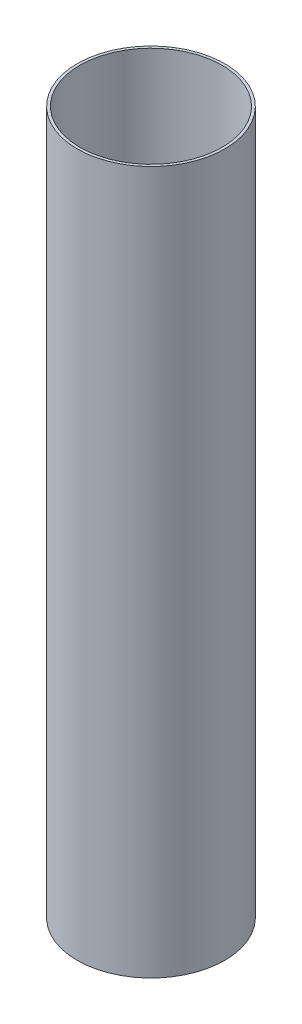
from build123d import *

# Parameters (mm, degrees)
SKETCH1_R               = 12
BOSS_EXTRUDE1_DEPTH     = 114.25
SKETCH2_R               = 11.565
CUT_EXTRUDE1_DEPTH      = 40
SKETCH3_R               = 3.3
CUT_EXTRUDE2_DEPTH      = 1
CUT_EXTRUDE2_DEPTH_BACK = 115.25


with BuildPart() as part:
    # Sketch1 → Boss-Extrude1 (new body)
    with BuildSketch(Plane(origin=(0, 0, 0), x_dir=(1, 0, 0), z_dir=(0, 1, 0))):
        Circle(SKETCH1_R)
    extrude(amount=BOSS_EXTRUDE1_DEPTH)

    # Sketch2 → Cut-Extrude1 (cut)
    with BuildSketch(Plane(origin=(0, 114.25, 0), x_dir=(1, 0, 0), z_dir=(0, 1, 0))):
        Circle(SKETCH2_R)
    extrude(amount=-CUT_EXTRUDE1_DEPTH, mode=Mode.SUBTRACT)

    # Sketch3 → Cut-Extrude2 (cut, two sides)
    with BuildSketch(Plane.XZ) as cut_extrude2_sk:
        Circle(SKETCH3_R)
    extrude(amount=CUT_EXTRUDE2_DEPTH, mode=Mode.SUBTRACT)
    extrude(cut_extrude2_sk.sketch, amount=-CUT_EXTRUDE2_DEPTH_BACK, mode=Mode.SUBTRACT)


solid = part.part
